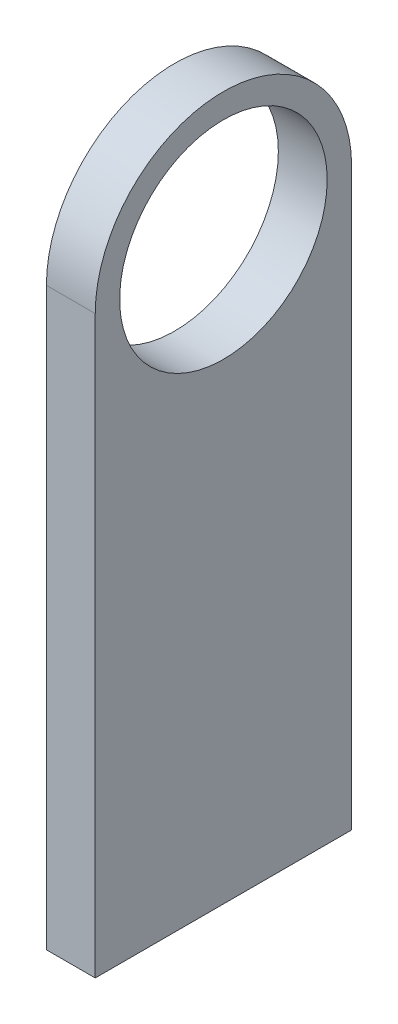
from build123d import *

# Parameters (mm, degrees)
SKETCH1_R           = 8.5
BOSS_EXTRUDE1_DEPTH = 4


with BuildPart() as part:
    # Sketch1 → Boss-Extrude1 (new body)
    with BuildSketch(Plane(origin=(0, 0, 0), x_dir=(0, 0, -1), z_dir=(1, 0, 0))):
        with BuildLine():
            Line((10.5, 0), (10.5, -47.137908156))
            Line((10.5, -47.137908156), (-10.5, -47.137908156))
            Line((-10.5, -47.137908156), (-10.5, 0))
            ThreePointArc((-10.5, 0), (0, 10.5), (10.5, 0))
        make_face()
        Circle(SKETCH1_R, mode=Mode.SUBTRACT)
    extrude(amount=BOSS_EXTRUDE1_DEPTH)


solid = part.part
